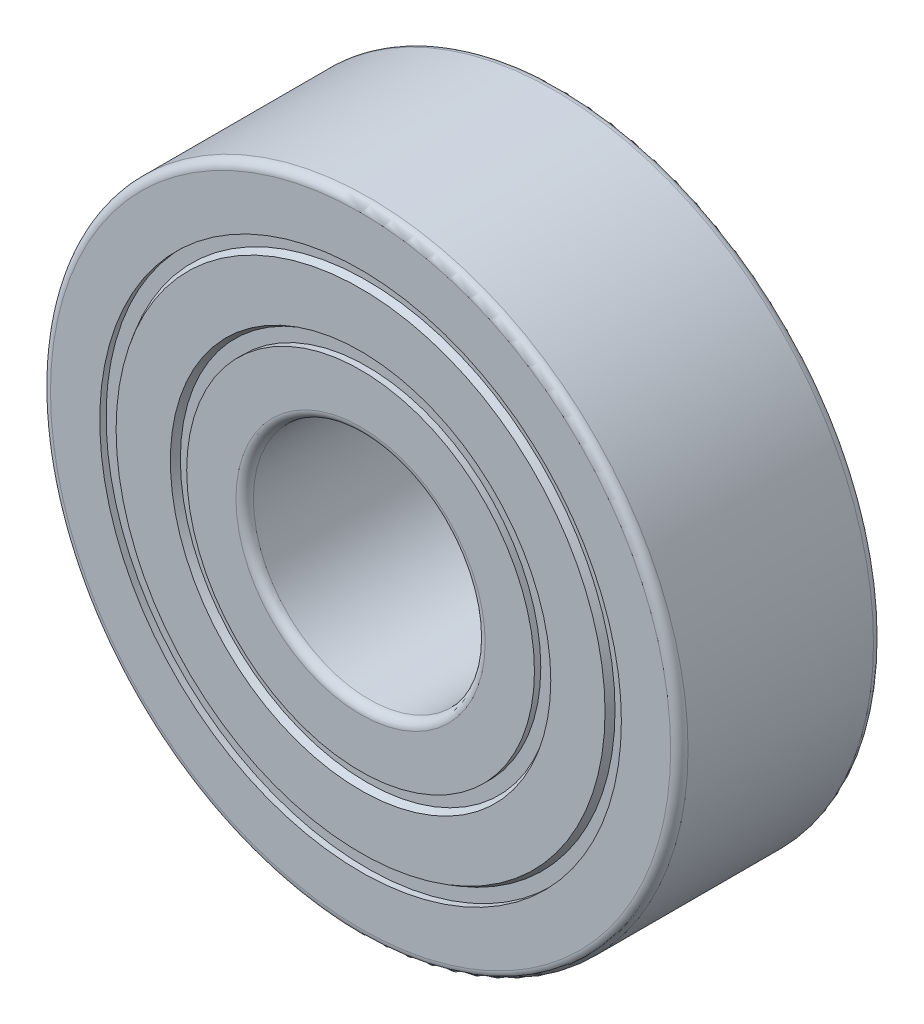
from build123d import *

# Parameters (mm, degrees)
SKETCH2_R = 2.1875


with BuildPart() as part:
    # Sketch2 → Base-Revolve (revolve)
    with BuildSketch(Plane(origin=(0, 0, 0), x_dir=(1, 0, 0), z_dir=(0, 1, 0))):
        with BuildLine():
            Line((-9, 0), (-9, -0.21875))
            Line((-9, -0.21875), (-8.5625, -0.21875))
            Line((-8.5625, -0.21875), (-8.436204629, 0))
            Line((-8.436204629, 0), (-6.563795371, 0))
            Line((-6.563795371, 0), (-6.4375, -0.21875))
            Line((-6.4375, -0.21875), (-6, -0.21875))
            Line((-6, -0.21875), (-6, 0))
            Line((-6, 0), (-4.3, 0))
            ThreePointArc((-4.3, 0), (-4.087867966, -0.087867966), (-4, -0.3))
            Line((-4, -0.3), (-4, -6.7))
            ThreePointArc((-4, -6.7), (-4.087867966, -6.912132034), (-4.3, -7))
            Line((-4.3, -7), (-6, -7))
            Line((-6, -7), (-6, -6.78125))
            Line((-6, -6.78125), (-6.4375, -6.78125))
            Line((-6.4375, -6.78125), (-6.563795371, -7))
            Line((-6.563795371, -7), (-8.436204629, -7))
            Line((-8.436204629, -7), (-8.5625, -6.78125))
            Line((-8.5625, -6.78125), (-9, -6.78125))
            Line((-9, -6.78125), (-9, -7))
            Line((-9, -7), (-10.7, -7))
            ThreePointArc((-10.7, -7), (-10.912132034, -6.912132034), (-11, -6.7))
            Line((-11, -6.7), (-11, -0.3))
            ThreePointArc((-11, -0.3), (-10.912132034, -0.087867966), (-10.7, 0))
            Line((-10.7, 0), (-9, 0))
        make_face()
        with Locations((-7.5, -3.5)):
            Circle(SKETCH2_R, mode=Mode.SUBTRACT)
    revolve(axis=Axis((0, 0, 19), (0, 0, -1)))


solid = part.part
